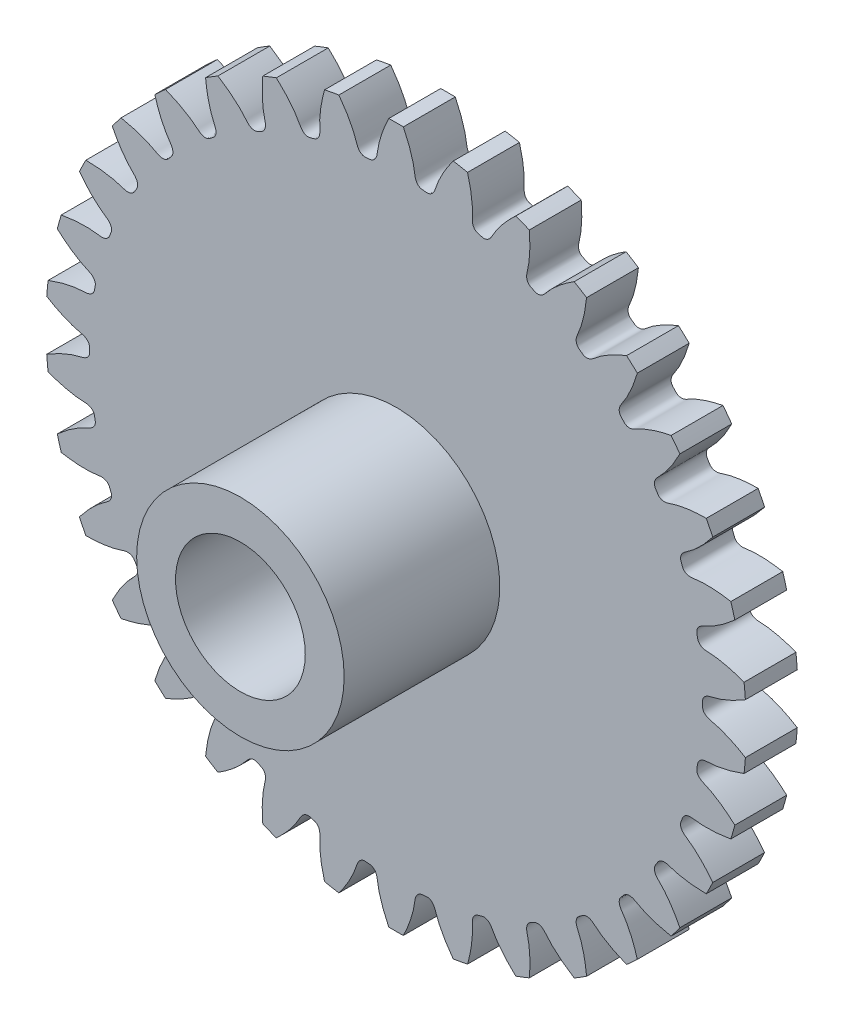
from build123d import *

# Parameters (mm, degrees)
SKETCHREVOLVESPUR02_W       = 0.500000008
SKETCHREVOLVESPUR02_H       = 3.375
TOOTHEXTRUDECUTSPUR02_DEPTH = 0.250000004
PATTERNSPUR02_COUNT         = 34
CROQUIS5_R                  = 1
SALIENTE_EXTRUIR1_DEPTH     = 1.5
CORTAR_EXTRUIR2_REACH       = 7.169
CROQUIS6_R                  = 0.625


with BuildPart() as part:
    # SketchRevolveSpur02 → Spur02 (revolve)
    with BuildSketch(Plane(origin=(0, 0, 0), x_dir=(0, 0, -1), z_dir=(1, 0, 0))):
        with Locations((0, 1.6875)):
            Rectangle(SKETCHREVOLVESPUR02_W, SKETCHREVOLVESPUR02_H)
    revolve(axis=Axis((0, 0, 0), (0, 0, -1)))

    # SketchToothSpur02 → ToothExtrudeCutSpur02 (cut, symmetric)
    with BuildSketch(Plane.XY):
        with BuildLine():
            ThreePointArc((3.375344675, 0.247067735), (3.384375, 0), (3.375344675, -0.247067735))
            add(Edge.make_bspline(
                [(3.375344675, -0.247067735), (3.347324519, -0.229609643), (3.310104235, -0.207994653), (3.263499242, -0.183775748), (3.237910772, -0.171197127), (3.213408473, -0.159825549), (3.190032891, -0.149605805), (3.167822603, -0.140481515), (3.146814278, -0.132394922), (3.1270424, -0.125288055), (3.108540042, -0.119099024), (3.091336164, -0.113774669), (3.075464435, -0.109228992), (3.058874915, -0.104947973), (3.045650704, -0.101671907), (3.03527826, -0.099700408), (3.029596482, -0.098379625), (3.024058343, -0.096943103), (3.018655548, -0.095354867), (3.013371009, -0.093607272), (3.008186774, -0.091678785), (3.003081824, -0.089542845), (2.998032872, -0.087162611), (2.993015135, -0.084488497), (2.988004537, -0.081453884), (2.982982151, -0.077970387), (2.977942501, -0.073923139), (2.972907836, -0.069168423), (2.967950203, -0.063538438), (2.963220474, -0.0568619), (2.958974418, -0.049009804), (2.955575833, -0.039973546), (2.953540668, -0.030440571), (2.95271568, -0.016988372), (2.953409778, 0), (2.95271568, 0.016988372), (2.953540668, 0.030440571), (2.955575833, 0.039973546), (2.958974418, 0.049009804), (2.963220474, 0.0568619), (2.967950203, 0.063538438), (2.972907836, 0.069168423), (2.977942501, 0.073923139), (2.982982151, 0.077970387), (2.988004537, 0.081453884), (2.993015135, 0.084488497), (2.998032872, 0.087162611), (3.003081824, 0.089542845), (3.008186774, 0.091678785), (3.013371009, 0.093607272), (3.018655548, 0.095354867), (3.024058343, 0.096943103), (3.029596482, 0.098379625), (3.03527826, 0.099700408), (3.045650704, 0.101671907), (3.058874915, 0.104947973), (3.075464435, 0.109228992), (3.091336164, 0.113774669), (3.108540042, 0.119099024), (3.1270424, 0.125288055), (3.146814278, 0.132394922), (3.167822603, 0.140481515), (3.190032891, 0.149605805), (3.213408473, 0.159825549), (3.237910772, 0.171197127), (3.263499242, 0.183775748), (3.310104235, 0.207994653), (3.347324519, 0.229609643), (3.375344675, 0.247067735)],
                knots=[0, 0, 0, 0, 0.095744637, 0.124759671, 0.152324101, 0.178437927, 0.20310115, 0.22631377, 0.248075786, 0.268387199, 0.287248008, 0.304658213, 0.320617816, 0.335126814, 0.354354247, 0.360112314, 0.365745289, 0.371269636, 0.376705131, 0.382075669, 0.387410276, 0.392744375, 0.398121341, 0.403594343, 0.409228388, 0.415102269, 0.421309715, 0.42795827, 0.435163242, 0.443032755, 0.451639893, 0.4609824, 0.470942443, 0.479783618, 0.5, 0.520216382, 0.529057557, 0.5390176, 0.548360107, 0.556967245, 0.564836758, 0.57204173, 0.578690285, 0.584897731, 0.590771612, 0.596405657, 0.601878659, 0.607255625, 0.612589724, 0.617924331, 0.623294869, 0.628730364, 0.634254711, 0.639887686, 0.645645753, 0.664873186, 0.679382184, 0.695341787, 0.712751992, 0.731612801, 0.751924214, 0.77368623, 0.79689885, 0.821562073, 0.847675899, 0.875240329, 0.904255363, 1, 1, 1, 1], degree=3))
        make_face()
    toothextrudecutspur02 = extrude(amount=TOOTHEXTRUDECUTSPUR02_DEPTH, both=True, mode=Mode.SUBTRACT)

    # PatternSpur02: ToothExtrudeCutSpur02 ×34 about axis
    patternspur02_axis = Axis((0, 0, 55), (0, 0, -1))
    for i in range(1, PATTERNSPUR02_COUNT):
        add(toothextrudecutspur02.rotate(patternspur02_axis, i * 360 / PATTERNSPUR02_COUNT), mode=Mode.SUBTRACT)

    # Croquis5 → Saliente-Extruir1 (add)
    with BuildSketch(Plane.XY.offset(0.250000004)):
        Circle(CROQUIS5_R)
    extrude(amount=SALIENTE_EXTRUIR1_DEPTH)

    # Croquis6 → Cortar-Extruir2 (cut, up to next)
    with BuildSketch(Plane.XY.offset(1.750000004), mode=Mode.PRIVATE) as cortar_extruir2_sk1:
        Circle(CROQUIS6_R)
    cortar_extruir2_tool1 = extrude(cortar_extruir2_sk1.sketch, amount=-CORTAR_EXTRUIR2_REACH, mode=Mode.PRIVATE) & part.part
    add(cortar_extruir2_tool1.solids().sort_by_distance((0, 0, 1.75))[0], mode=Mode.SUBTRACT)


solid = part.part
